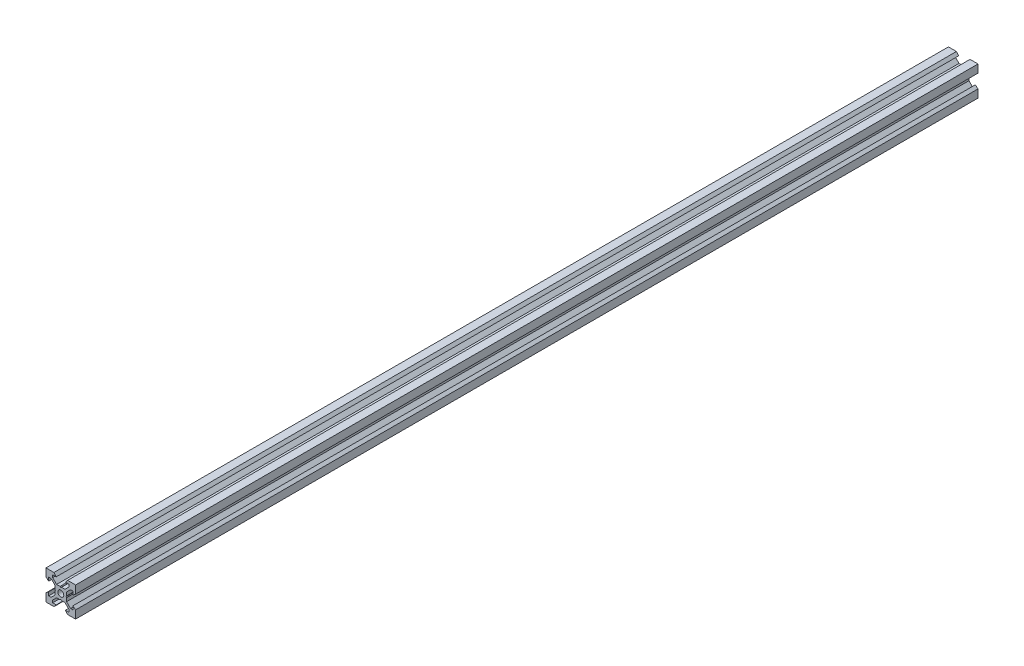
from build123d import *

# Parameters (mm, degrees)
SKETCH1_R           = 2
BOSS_EXTRUDE1_DEPTH = 305


with BuildPart() as part:
    # Sketch1 → Boss-Extrude1 (new body, symmetric)
    with BuildSketch(Plane.XY):
        Polygon((10, 10), (10, 4.610379336), (8.2, 3.1), (8.2, 5.5), (6.560660172, 5.5), (3.9, 2.839339828), (3.9, 0.519615242), (3.6, 0), (3.9, -0.519615242), (3.9, -2.839339828), (6.560660172, -5.5), (8.2, -5.5), (8.2, -3.1), (10, -4.610379336), (10, -10), (4.610379336, -10), (3.1, -8.2), (5.5, -8.2), (5.5, -6.560660172), (2.839339828, -3.9), (0.519615242, -3.9), (0, -3.6), (-0.519615242, -3.9), (-2.839339828, -3.9), (-5.5, -6.560660172), (-5.5, -8.2), (-3.1, -8.2), (-4.610379336, -10), (-10, -10), (-10, -4.610379336), (-8.2, -3.1), (-8.2, -5.5), (-6.560660172, -5.5), (-3.9, -2.839339828), (-3.9, -0.519615242), (-3.6, 0), (-3.9, 0.519615242), (-3.9, 2.839339828), (-6.560660172, 5.5), (-8.2, 5.5), (-8.2, 3.1), (-10, 4.610379336), (-10, 10), (-4.610379336, 10), (-3.1, 8.2), (-5.5, 8.2), (-5.5, 6.560660172), (-2.839339828, 3.9), (-0.519615242, 3.9), (0, 3.6), (0.519615242, 3.9), (2.839339828, 3.9), (5.5, 6.560660172), (5.5, 8.2), (3.1, 8.2), (4.610379336, 10), align=None)
        Circle(SKETCH1_R, mode=Mode.SUBTRACT)
    extrude(amount=BOSS_EXTRUDE1_DEPTH, both=True)


solid = part.part
